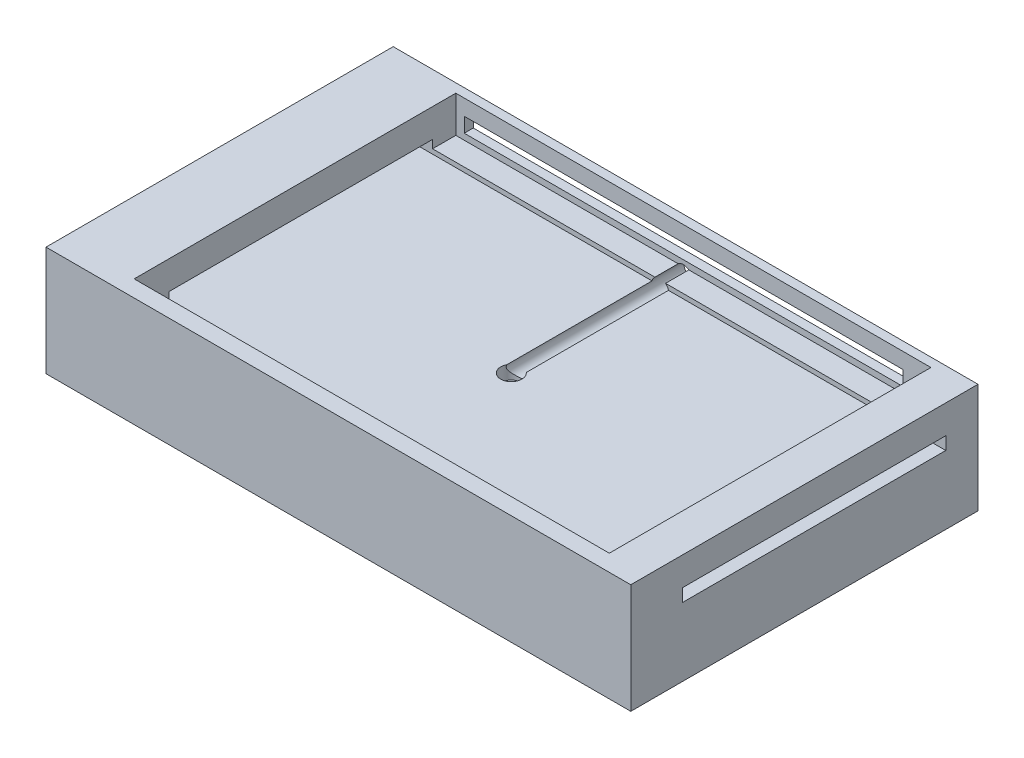
from build123d import *

# Parameters (mm, degrees)
SKETCH1_W               = 160
SKETCH1_H               = 95
BOSS_EXTRUDE1_DEPTH     = 30
SKETCH3_W               = 130
SKETCH3_H               = 88
CUT_EXTRUDE1_DEPTH      = 10
SKETCH4_W               = 120.10834505
SKETCH4_H               = 4.01773352
CUT_EXTRUDE2_DEPTH      = 5
CUT_EXTRUDE4_START      = 10
SKETCH6_W               = 72.05939184
SKETCH6_H               = 3.5
CUT_EXTRUDE4_DEPTH      = 1
CUT_EXTRUDE4_DEPTH_BACK = 171
SKETCH7_R               = 2.3
CUT_EXTRUDE5_DEPTH      = 50
SKETCH8_R               = 2.907178759
CUT_EXTRUDE6_DEPTH      = 5


with BuildPart() as part:
    # Sketch1 → Boss-Extrude1 (new body)
    with BuildSketch(Plane(origin=(0, 0, 0), x_dir=(1, 0, 0), z_dir=(0, 1, 0))):
        with Locations((-0.236733524, -14.477499078)):
            Rectangle(SKETCH1_W, SKETCH1_H)
    extrude(amount=BOSS_EXTRUDE1_DEPTH)

    # Sketch3 → Cut-Extrude1 (cut)
    with BuildSketch(Plane(origin=(0, 30, 0), x_dir=(1, 0, 0), z_dir=(0, 1, 0))):
        with Locations((4.347428577, -13.440922118)):
            Rectangle(SKETCH3_W, SKETCH3_H)
    extrude(amount=-CUT_EXTRUDE1_DEPTH, mode=Mode.SUBTRACT)

    # Sketch4 → Cut-Extrude2 (cut)
    with BuildSketch(Plane(origin=(0, 0, -33.022500922), x_dir=(-1, 0, 0), z_dir=(0, 0, -1))):
        with Locations((-1.719856556, 23.682368484)):
            Rectangle(SKETCH4_W, SKETCH4_H)
    extrude(amount=-CUT_EXTRUDE2_DEPTH, mode=Mode.SUBTRACT)

    # Sketch6 → Cut-Extrude4 (cut, two sides)
    with BuildSketch(Plane(origin=(79.763266476, 0, 0), x_dir=(0, 0, -1), z_dir=(1, 0, 0)).offset(CUT_EXTRUDE4_START)) as cut_extrude4_sk:
        with Locations((-11.823423429, 20.472568853)):
            Rectangle(SKETCH6_W, SKETCH6_H)
    extrude(amount=CUT_EXTRUDE4_DEPTH, mode=Mode.SUBTRACT)
    extrude(cut_extrude4_sk.sketch, amount=-CUT_EXTRUDE4_DEPTH_BACK, mode=Mode.SUBTRACT)

    # Sketch7 → Cut-Extrude5 (cut)
    with BuildSketch(Plane(origin=(-65.187547899, 5.789113432, -33.022500922), x_dir=(-1, 0, 0), z_dir=(0, 0, -1))):
        with Locations((-66.824710363, 12.43513753)):
            Circle(SKETCH7_R)
    extrude(amount=-CUT_EXTRUDE5_DEPTH, mode=Mode.SUBTRACT)

    # Sketch8 → Cut-Extrude6 (cut)
    with BuildSketch(Plane(origin=(0, 20, 0), x_dir=(1, 0, 0), z_dir=(0, 1, 0))):
        with Locations((1.966492652, -16.875229275)):
            Circle(SKETCH8_R)
    extrude(amount=-CUT_EXTRUDE6_DEPTH, mode=Mode.SUBTRACT)


solid = part.part
